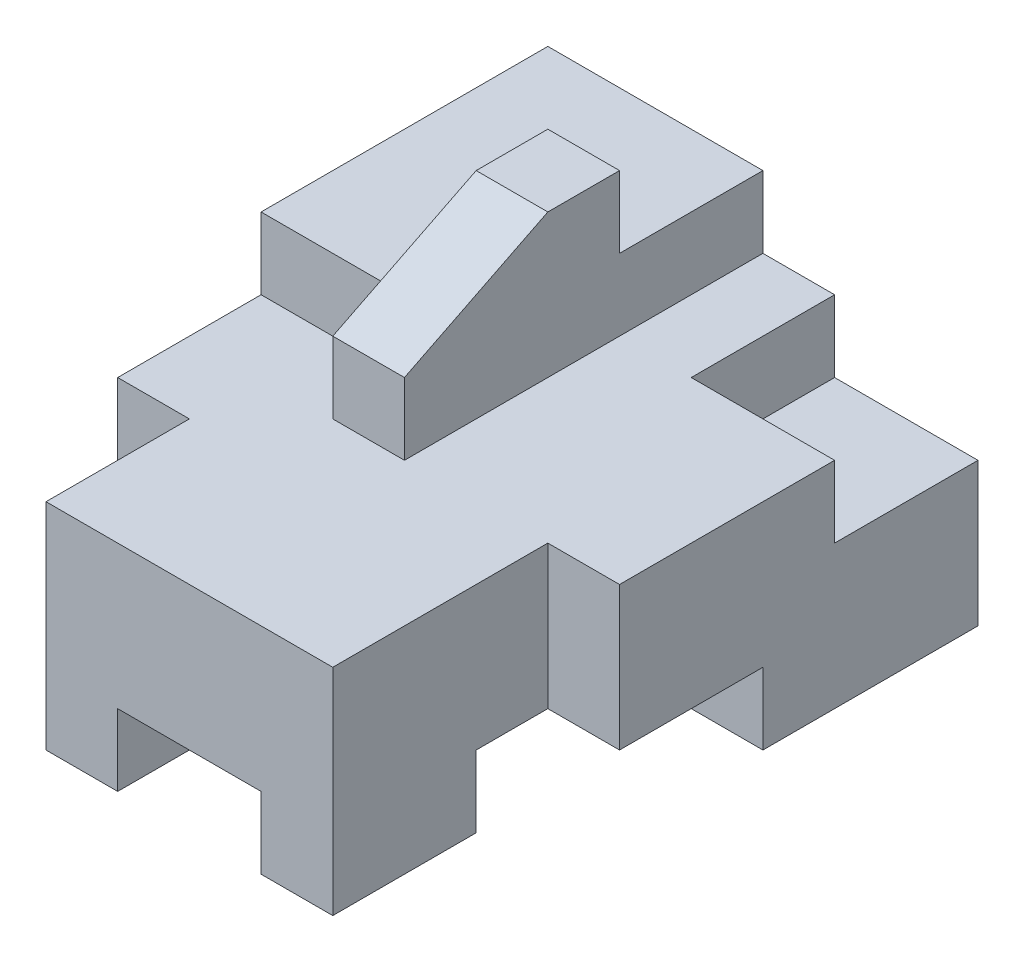
from build123d import *

# Parameters (mm, degrees)
SKETCH1_W           = 6
SKETCH1_H           = 4
BOSS_EXTRUDE1_DEPTH = 8
SKETCH2_W           = 2
SKETCH2_H           = 1
CUT_EXTRUDE1_DEPTH  = 9
SKETCH3_W           = 1
SKETCH3_H           = 2
SKETCH3_H_2         = 3
CUT_EXTRUDE2_DEPTH  = 5
SKETCH4_W           = 3
SKETCH4_H           = 1
CUT_EXTRUDE3_DEPTH  = 7
SKETCH5_OUTSIDE_W   = 10.154
SKETCH5_OUTSIDE_H   = 12.154
CUT_EXTRUDE4_DEPTH  = 1
SKETCH6_W           = 2
SKETCH6_H           = 2
CUT_EXTRUDE5_DEPTH  = 1
SKETCH7_W           = 1
SKETCH7_H           = 3
BOSS_EXTRUDE2_DEPTH = 1
CUT_EXTRUDE6_DEPTH  = 4


with BuildPart() as part:
    # Sketch1 → Boss-Extrude1 (new body)
    with BuildSketch(Plane.XY):
        Rectangle(SKETCH1_W, SKETCH1_H)
    extrude(amount=BOSS_EXTRUDE1_DEPTH)

    # Sketch2 → Cut-Extrude1 (cut, through all)
    with BuildSketch(Plane.XY.offset(8)):
        with Locations((0, -1.5)):
            Rectangle(SKETCH2_W, SKETCH2_H)
    extrude(amount=-CUT_EXTRUDE1_DEPTH, mode=Mode.SUBTRACT)

    # Sketch3 → Cut-Extrude2 (cut, through all)
    with BuildSketch(Plane(origin=(0, 2, 0), x_dir=(1, 0, 0), z_dir=(0, 1, 0))):
        with Locations((-2.5, -7)):
            Rectangle(SKETCH3_W, SKETCH3_H)
        with Locations((2.5, -6.5)):
            Rectangle(SKETCH3_W, SKETCH3_H_2)
    extrude(amount=-CUT_EXTRUDE2_DEPTH, mode=Mode.SUBTRACT)

    # Sketch4 → Cut-Extrude3 (cut, through all)
    with BuildSketch(Plane(origin=(3, 0, 0), x_dir=(0, 0, -1), z_dir=(1, 0, 0))):
        with Locations((-4.5, -1.5)):
            Rectangle(SKETCH4_W, SKETCH4_H)
    extrude(amount=-CUT_EXTRUDE3_DEPTH, mode=Mode.SUBTRACT)

    # Sketch5 outside → Cut-Extrude4 (cut)
    with BuildSketch(Plane(origin=(0, 2, 0), x_dir=(1, 0, 0), z_dir=(0, 1, 0))):
        with Locations((0, -4)):
            Rectangle(SKETCH5_OUTSIDE_W, SKETCH5_OUTSIDE_H)
        Polygon((-3, 0), (0, 0), (0, -5), (-1, -5), (-1, -4), (-3, -4), align=None, mode=Mode.SUBTRACT)
    extrude(amount=-CUT_EXTRUDE4_DEPTH, mode=Mode.SUBTRACT)

    # Sketch6 → Cut-Extrude5 (cut)
    with BuildSketch(Plane(origin=(0, 1, 0), x_dir=(1, 0, 0), z_dir=(0, 1, 0))):
        with Locations((2, -1)):
            Rectangle(SKETCH6_W, SKETCH6_H)
    extrude(amount=-CUT_EXTRUDE5_DEPTH, mode=Mode.SUBTRACT)

    # Sketch7 → Boss-Extrude2 (add)
    with BuildSketch(Plane(origin=(0, 2, 0), x_dir=(1, 0, 0), z_dir=(0, 1, 0))):
        with Locations((-0.5, -3.5)):
            Rectangle(SKETCH7_W, SKETCH7_H)
    extrude(amount=BOSS_EXTRUDE2_DEPTH)

    # Sketch8 → Cut-Extrude6 (cut, through all)
    with BuildSketch(Plane(origin=(0, 0, 0), x_dir=(0, 0, -1), z_dir=(1, 0, 0))):
        Polygon((-3, 3), (-5, 2), (-5, 3), align=None)
    extrude(amount=-CUT_EXTRUDE6_DEPTH, mode=Mode.SUBTRACT)


solid = part.part
